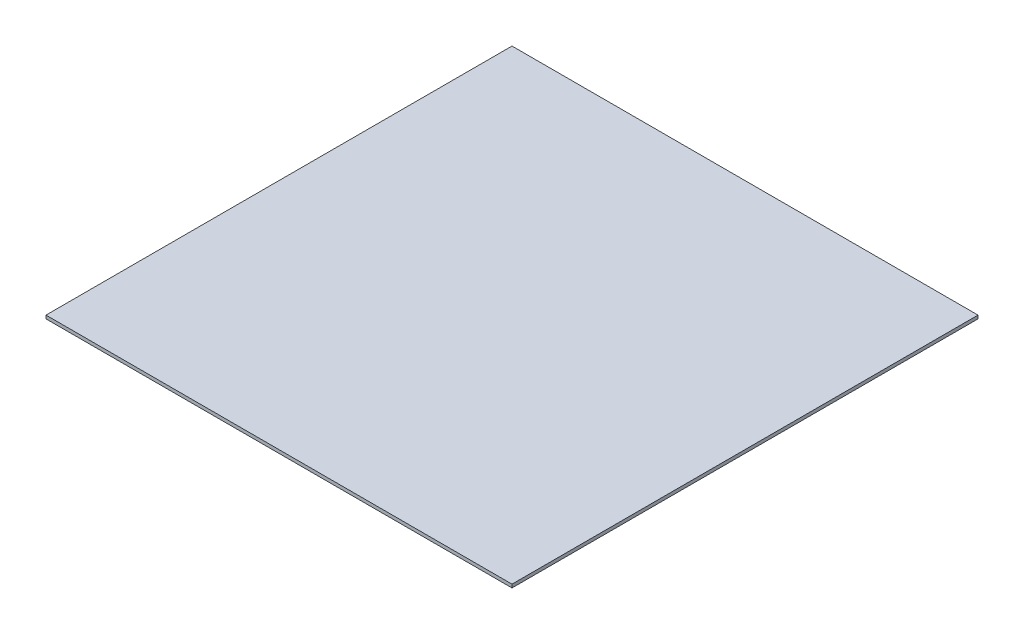
from build123d import *

# Parameters (mm, degrees)
SKETCH1_W           = 107.07
SKETCH1_H           = 107.07
BOSS_EXTRUDE1_DEPTH = 0.762
SCALE1_SCALE        = 0.5


with BuildPart() as part:
    # Sketch1 → Boss-Extrude1 (new body)
    with BuildSketch(Plane(origin=(0, 0, 0), x_dir=(1, 0, 0), z_dir=(0, 1, 0))):
        with Locations((53.535, 53.535)):
            Rectangle(SKETCH1_W, SKETCH1_H)
    extrude(amount=BOSS_EXTRUDE1_DEPTH)


with BuildPart() as part_1:
    # Scale1: scaled about (53.535, 0.381, -53.535)
    add(part.part.scale(SCALE1_SCALE).moved(Location((26.7675, 0.1905, -26.7675))))


solid = part_1.part
